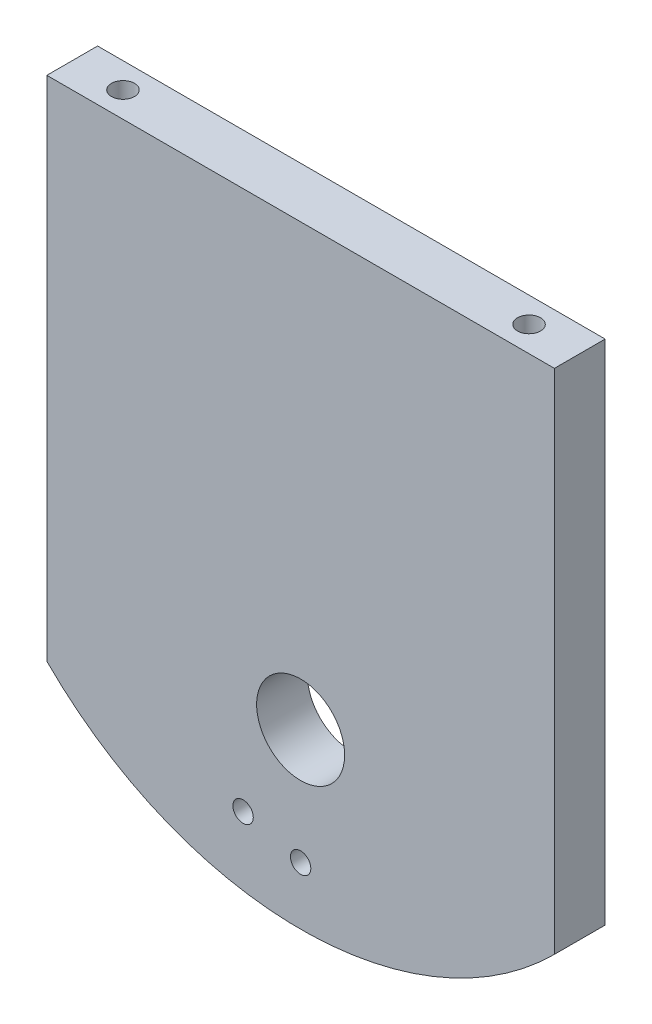
from build123d import *

# Parameters (mm, degrees)
SKETCH2_W                        = 150
SKETCH2_H                        = 90
SKETCH2_H_2                      = 60
BOSS_EXTRUDE1_DEPTH              = 15
SKETCH3_R                        = 13.005
SKETCH3_R_2                      = 3.01
CUT_EXTRUDE1_DEPTH               = 16
TAP_DRILL_FOR_M8X1_25_TAP1_D     = 6.8
TAP_DRILL_FOR_M8X1_25_TAP1_DEPTH = 10
TAP_DRILL_FOR_M8X1_25_TAP1_TIP   = 2.042926105
TAP_DRILL_FOR_M8X1_25_TAP2_D     = 6.8
TAP_DRILL_FOR_M8X1_25_TAP2_DEPTH = 40
TAP_DRILL_FOR_M8X1_25_TAP2_TIP   = 2.042926105


with BuildPart() as part:
    # Sketch2 → Boss-Extrude1 (new body)
    with BuildSketch(Plane.XY):
        Rectangle(SKETCH2_W, SKETCH2_H)
        with Locations((0, -75)):
            Rectangle(SKETCH2_W, SKETCH2_H_2)
        with BuildLine():
            Line((-75, -105), (75, -105))
            ThreePointArc((75, -105), (0, -136.066017178), (-75, -105))
        make_face()
    extrude(amount=BOSS_EXTRUDE1_DEPTH)

    # Sketch3 → Cut-Extrude1 (cut, through all)
    with BuildSketch(Plane.XY.offset(15)):
        with Locations((0, -85)):
            Circle(SKETCH3_R)
        with Locations((-17, -114.444863729)):
            Circle(SKETCH3_R_2)
        with Locations((0, -119)):
            Circle(SKETCH3_R_2)
    extrude(amount=-CUT_EXTRUDE1_DEPTH, mode=Mode.SUBTRACT)

    # Tap Drill for M8x1.25 Tap1
    with Locations(Plane(origin=(0, 0, 0), x_dir=(-1, 0, 0), z_dir=(0, 0, -1))):
        with Locations((-37.5, -50), (37.5, -50)):
            Hole(TAP_DRILL_FOR_M8X1_25_TAP1_D / 2, depth=TAP_DRILL_FOR_M8X1_25_TAP1_DEPTH)
            with Locations((0, 0, -(TAP_DRILL_FOR_M8X1_25_TAP1_DEPTH + TAP_DRILL_FOR_M8X1_25_TAP1_TIP / 2))):  # 118° drill point
                Cone(0, TAP_DRILL_FOR_M8X1_25_TAP1_D / 2, TAP_DRILL_FOR_M8X1_25_TAP1_TIP, mode=Mode.SUBTRACT)

    # Tap Drill for M8x1.25 Tap2
    with Locations(Plane(origin=(0, 45, 0), x_dir=(1, 0, 0), z_dir=(0, 1, 0))):
        with Locations((-60, -7.5), (60, -7.5)):
            Hole(TAP_DRILL_FOR_M8X1_25_TAP2_D / 2, depth=TAP_DRILL_FOR_M8X1_25_TAP2_DEPTH)
            with Locations((0, 0, -(TAP_DRILL_FOR_M8X1_25_TAP2_DEPTH + TAP_DRILL_FOR_M8X1_25_TAP2_TIP / 2))):  # 118° drill point
                Cone(0, TAP_DRILL_FOR_M8X1_25_TAP2_D / 2, TAP_DRILL_FOR_M8X1_25_TAP2_TIP, mode=Mode.SUBTRACT)


solid = part.part
